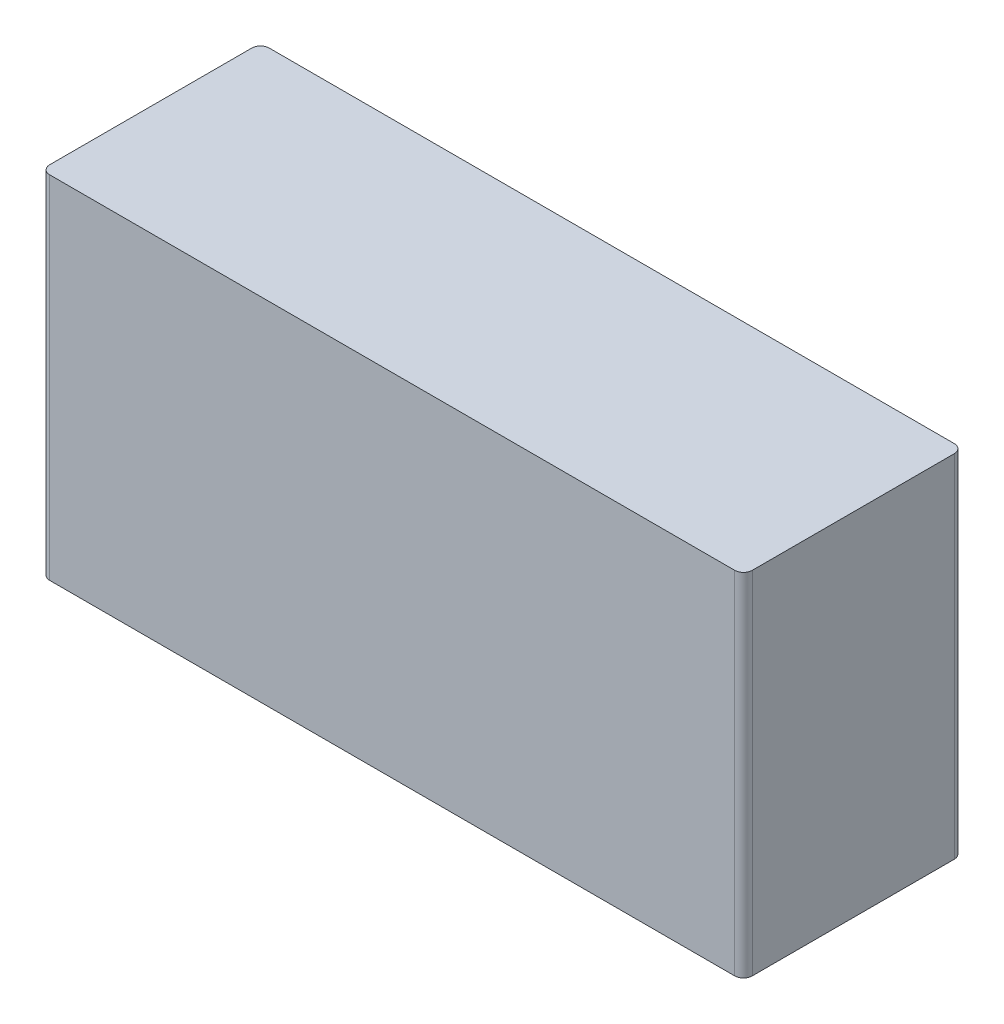
from build123d import *

# Parameters (mm, degrees)
SKETCH1_W           = 80
SKETCH1_H           = 40
BOSS_EXTRUDE1_DEPTH = 25
FILLET3_R           = 1
FILLET4_R           = 1


with BuildPart() as part:
    # Sketch1 → Boss-Extrude1 (new body)
    with BuildSketch(Plane.XY):
        with Locations((40, 20)):
            Rectangle(SKETCH1_W, SKETCH1_H)
    extrude(amount=BOSS_EXTRUDE1_DEPTH)

    # Fillet3
    fillet3_edges = [part.edges().sort_by_distance(p)[0] for p in [
        (0, 20, 25),
    ]]
    fillet(fillet3_edges, radius=FILLET3_R)

    # Fillet4
    fillet4_edges = [part.edges().sort_by_distance(p)[0] for p in [
        (80, 20, 25),
        (80, 20, 0),
        (0, 20, 0),
    ]]
    fillet(fillet4_edges, radius=FILLET4_R)


solid = part.part
